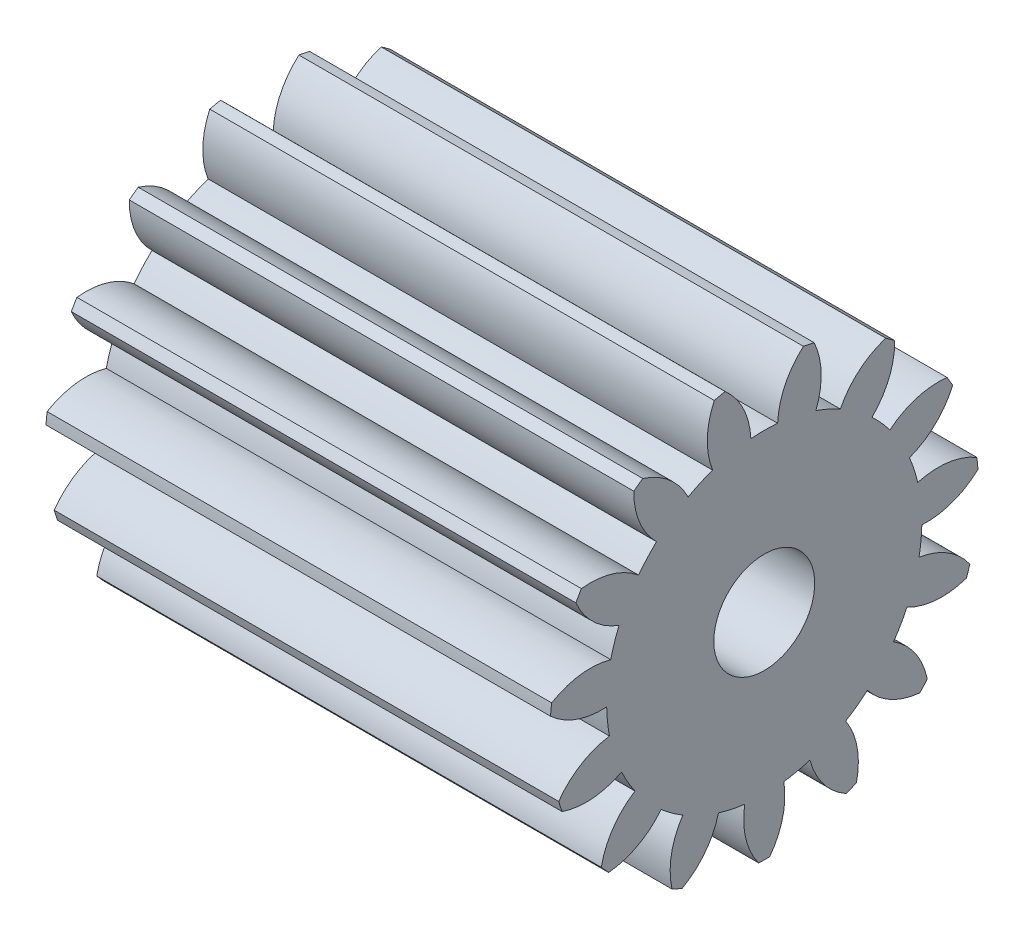
from build123d import *

# Parameters (mm, degrees)
BASPROSKE_W     = 10
BASPROSKE_H     = 4.25
TOOTHCUT_DEPTH  = 12.66726189
TEETHCUTS_COUNT = 15
TEETHCUTS_ANGLE = 336
BORSKE_R        = 1
BORE_DEPTH      = 50.0000508


with BuildPart() as part:
    # BasProSke → Base-Revolve (revolve)
    with BuildSketch(Plane(origin=(0, 0, 0), x_dir=(1, 0, 0), z_dir=(0, 1, 0)), mode=Mode.PRIVATE) as base_revolve_sk:
        with Locations((5, 2.125)):
            Rectangle(BASPROSKE_W, BASPROSKE_H)
    revolve(base_revolve_sk.sketch.rotate(Axis((-10, 0, 0), (1, 0, 0)), 180), axis=Axis((-10, 0, 0), (1, 0, 0)))

    # TooCutSke → ToothCut (cut, through all)
    with BuildSketch(Plane(origin=(0, 0, 0), x_dir=(0, 0, -1), z_dir=(1, 0, 0))):
        with BuildLine():
            ThreePointArc((0.265767165, 3.112674704), (0, 3.124), (-0.265767165, 3.112674704))
            ThreePointArc((-0.265767165, 3.112674704), (-0.418628877, 3.712626775), (-0.800767345, 4.19974009))
            ThreePointArc((-0.800767345, 4.19974009), (0, 4.2754), (0.800767345, 4.19974009))
            ThreePointArc((0.800767345, 4.19974009), (0.418628877, 3.712626775), (0.265767165, 3.112674704))
        make_face()
    toothcut = extrude(amount=TOOTHCUT_DEPTH, mode=Mode.SUBTRACT)

    # TeethCuts: ToothCut ×15 about axis
    teethcuts_axis = Axis((-10, 0, 0), (1, 0, 0))
    for i in range(1, TEETHCUTS_COUNT):
        add(toothcut.rotate(teethcuts_axis, i * TEETHCUTS_ANGLE / (TEETHCUTS_COUNT - 1)), mode=Mode.SUBTRACT)

    # BorSke → Bore (cut, symmetric)
    with BuildSketch(Plane(origin=(0, 0, 0), x_dir=(0, 0, -1), z_dir=(1, 0, 0))):
        with Locations(Location((0, 0, 0), (0, 0, 180))):
            Circle(BORSKE_R)
    extrude(amount=BORE_DEPTH, both=True, mode=Mode.SUBTRACT)


solid = part.part
